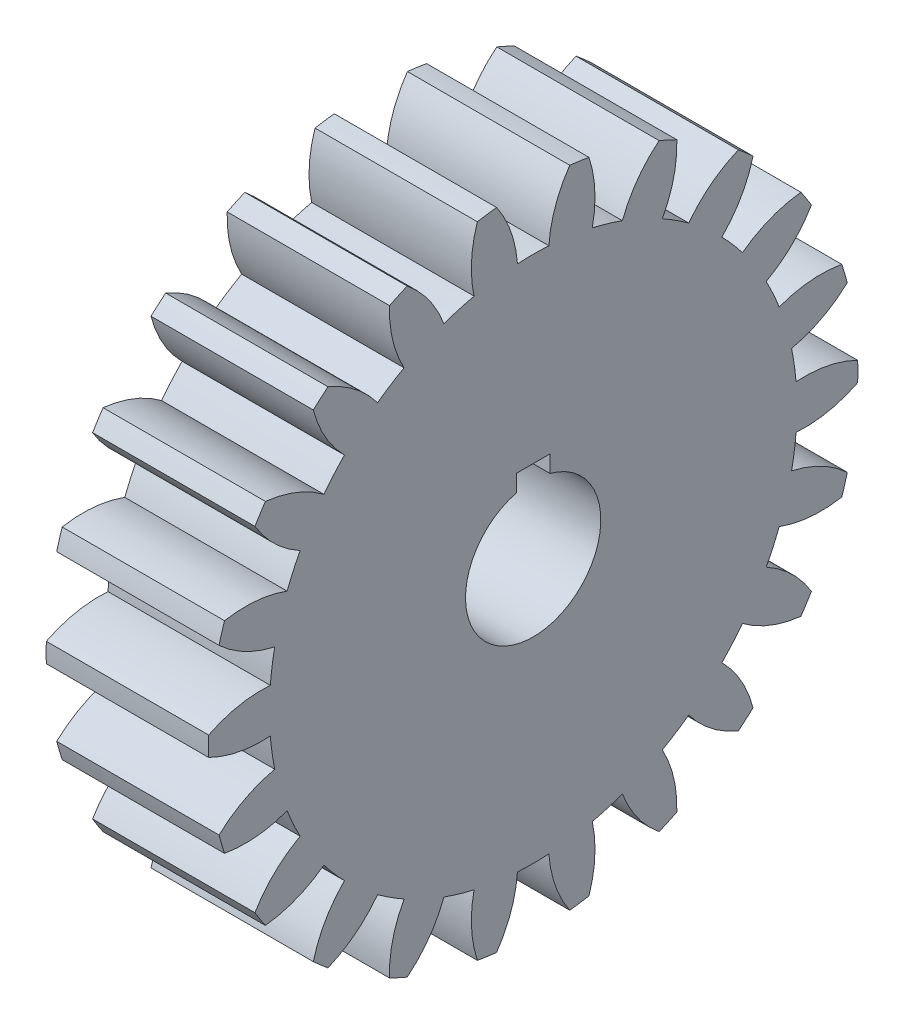
from build123d import *

# Parameters (mm, degrees)
BASPROSKE_W     = 304.8
BASPROSKE_H     = 609.6
TOOTHCUT_DEPTH  = 915.4
TEETHCUTS_COUNT = 22
TEETHCUTS_ANGLE = 343.636363636
BORSKE_R        = 127
BORE_DEPTH      = 304.8000508
KEYSKE_W        = 63.5
KEYSKE_H        = 154.8384
KEYWAY_DEPTH    = 304.8000508


with BuildPart() as part:
    # BasProSke → Base-Revolve (revolve)
    with BuildSketch(Plane(origin=(0, 0, 0), x_dir=(1, 0, 0), z_dir=(0, 1, 0)), mode=Mode.PRIVATE) as base_revolve_sk:
        with Locations((152.4, 304.8)):
            Rectangle(BASPROSKE_W, BASPROSKE_H)
    revolve(base_revolve_sk.sketch.rotate(Axis((-10, 0, 0), (1, 0, 0)), 180), axis=Axis((-10, 0, 0), (1, 0, 0)))

    # TooCutSke → ToothCut (cut, through all)
    with BuildSketch(Plane(origin=(0, 0, 0), x_dir=(0, 0, -1), z_dir=(1, 0, 0))):
        with BuildLine():
            ThreePointArc((29.477931626, 494.420755518), (0, 495.29873), (-29.477931626, 494.420755518))
            ThreePointArc((-29.477931626, 494.420755518), (-41.591539093, 552.716510617), (-68.665781689, 605.74593581))
            ThreePointArc((-68.665781689, 605.74593581), (0, 609.6254), (68.665781689, 605.74593581))
            ThreePointArc((68.665781689, 605.74593581), (41.591539093, 552.716510617), (29.477931626, 494.420755518))
        make_face()
    toothcut = extrude(amount=TOOTHCUT_DEPTH, mode=Mode.SUBTRACT)

    # TeethCuts: ToothCut ×22 about axis
    teethcuts_axis = Axis((-10, 0, 0), (1, 0, 0))
    for i in range(1, TEETHCUTS_COUNT):
        add(toothcut.rotate(teethcuts_axis, i * TEETHCUTS_ANGLE / (TEETHCUTS_COUNT - 1)), mode=Mode.SUBTRACT)

    # BorSke → Bore (cut, symmetric)
    with BuildSketch(Plane(origin=(0, 0, 0), x_dir=(0, 0, -1), z_dir=(1, 0, 0))):
        with Locations(Location((0, 0, 0), (0, 0, 180))):
            Circle(BORSKE_R)
    extrude(amount=BORE_DEPTH, both=True, mode=Mode.SUBTRACT)

    # KeySke → Keyway (cut, symmetric)
    with BuildSketch(Plane(origin=(0, 0, 0), x_dir=(0, 0, -1), z_dir=(1, 0, 0))):
        with Locations((0, 77.4192)):
            Rectangle(KEYSKE_W, KEYSKE_H)
    extrude(amount=KEYWAY_DEPTH, both=True, mode=Mode.SUBTRACT)


solid = part.part
